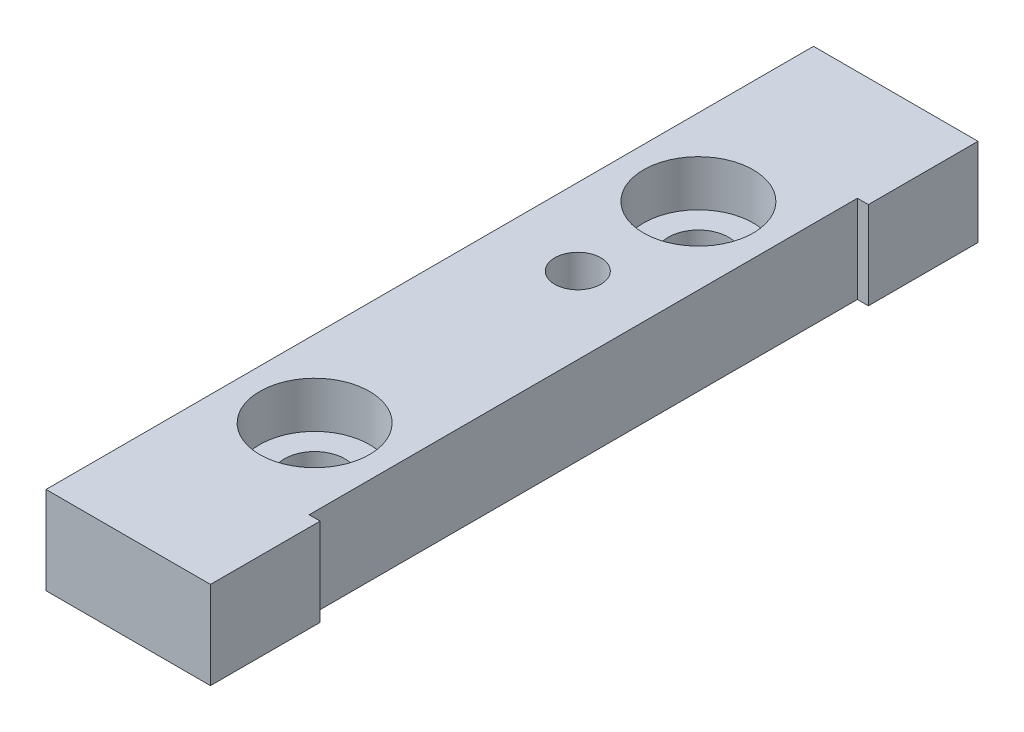
from build123d import *

# Parameters (mm, degrees)
BOSS_EXTRUDE1_DEPTH = 8
SKETCH2_R           = 2.75
CUT_EXTRUDE1_DEPTH  = 9
SKETCH3_R           = 5
CUT_EXTRUDE2_DEPTH  = 4.2
M5_TAPPED_HOLE1_D   = 4.2


with BuildPart() as part:
    # Sketch1 → Boss-Extrude1 (new body)
    with BuildSketch(Plane(origin=(0, 0, 0), x_dir=(1, 0, 0), z_dir=(0, 1, 0))):
        Polygon((7.5, 25), (6.5, 25), (6.5, -25), (7.5, -25), (7.5, -35), (-7.5, -35), (-7.5, 35), (7.5, 35), align=None)
    extrude(amount=BOSS_EXTRUDE1_DEPTH)

    # Sketch2 → Cut-Extrude1 (cut, through all)
    with BuildSketch(Plane(origin=(0, 8, 0), x_dir=(1, 0, 0), z_dir=(0, 1, 0))):
        with Locations((-0.5, 17.5)):
            Circle(SKETCH2_R)
        with Locations((-0.5, -17.5)):
            Circle(SKETCH2_R)
    extrude(amount=-CUT_EXTRUDE1_DEPTH, mode=Mode.SUBTRACT)

    # Sketch3 → Cut-Extrude2 (cut)
    with BuildSketch(Plane(origin=(0, 8, 0), x_dir=(1, 0, 0), z_dir=(0, 1, 0))):
        with Locations((-0.5, 17.5)):
            Circle(SKETCH3_R)
        with Locations((-0.5, -17.5)):
            Circle(SKETCH3_R)
    extrude(amount=-CUT_EXTRUDE2_DEPTH, mode=Mode.SUBTRACT)

    # M5 Tapped Hole1 (through all)
    with Locations(Plane(origin=(0, 8, 0), x_dir=(1, 0, 0), z_dir=(0, 1, 0))):
        with Locations((-0.5, 6.5)):
            Hole(M5_TAPPED_HOLE1_D / 2)


solid = part.part
